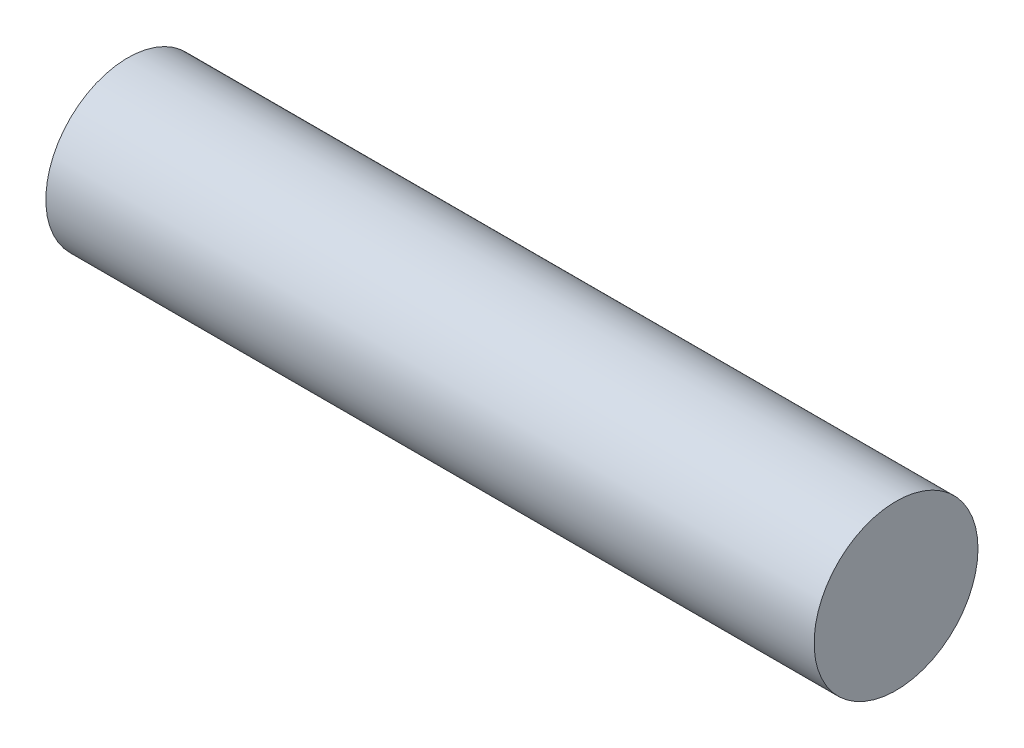
from build123d import *

# Parameters (mm, degrees)
SKETCH1_R           = 4
BOSS_EXTRUDE1_DEPTH = 37.5


with BuildPart() as part:
    # Sketch1 → Boss-Extrude1 (new body)
    with BuildSketch(Plane(origin=(0, 0, 0), x_dir=(0, 0, -1), z_dir=(1, 0, 0))):
        Circle(SKETCH1_R)
    extrude(amount=BOSS_EXTRUDE1_DEPTH)


solid = part.part
